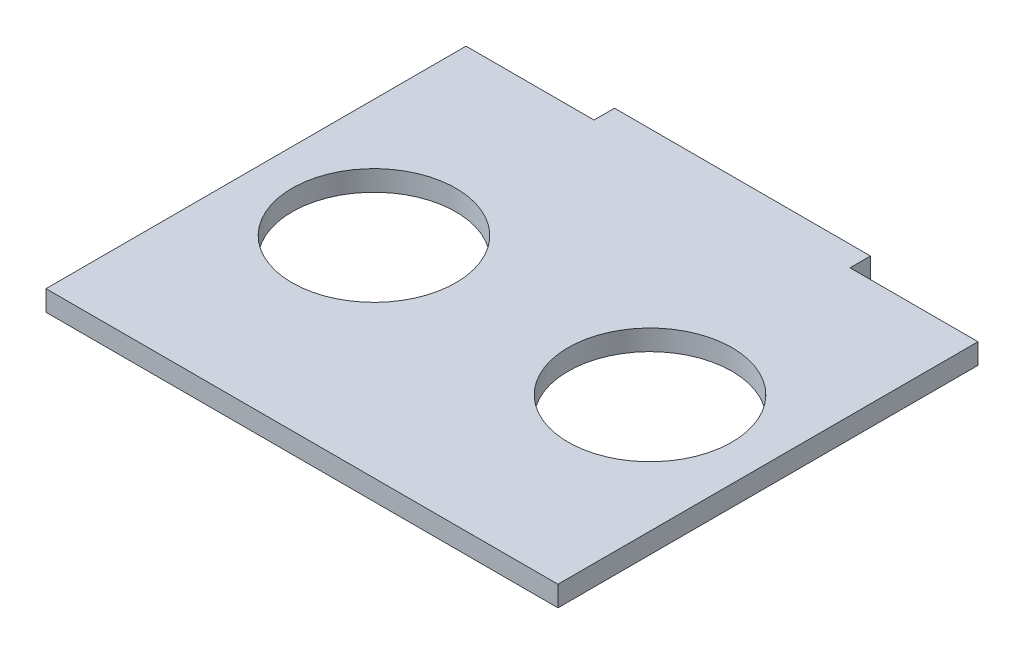
from build123d import *

# Parameters (mm, degrees)
SKETCH_1_R      = 8
EXTRUDE_1_DEPTH = 2


with BuildPart() as part:
    # 草圖1 → 填料-伸長1 (new body)
    with BuildSketch(Plane(origin=(0, 0, 0), x_dir=(1, 0, 0), z_dir=(0, 1, 0))):
        Polygon((12.5, 20.511459459), (25, 20.511459459), (25, -20.511459459), (-25, -20.511459459), (-25, 20.511459459), (-12.5, 20.511459459), (-12.5, 22.511459459), (12.5, 22.511459459), align=None)
        with Locations((-13.48, 0)):
            Circle(SKETCH_1_R, mode=Mode.SUBTRACT)
        with Locations((13.48, 0)):
            Circle(SKETCH_1_R, mode=Mode.SUBTRACT)
    extrude(amount=EXTRUDE_1_DEPTH)


solid = part.part
